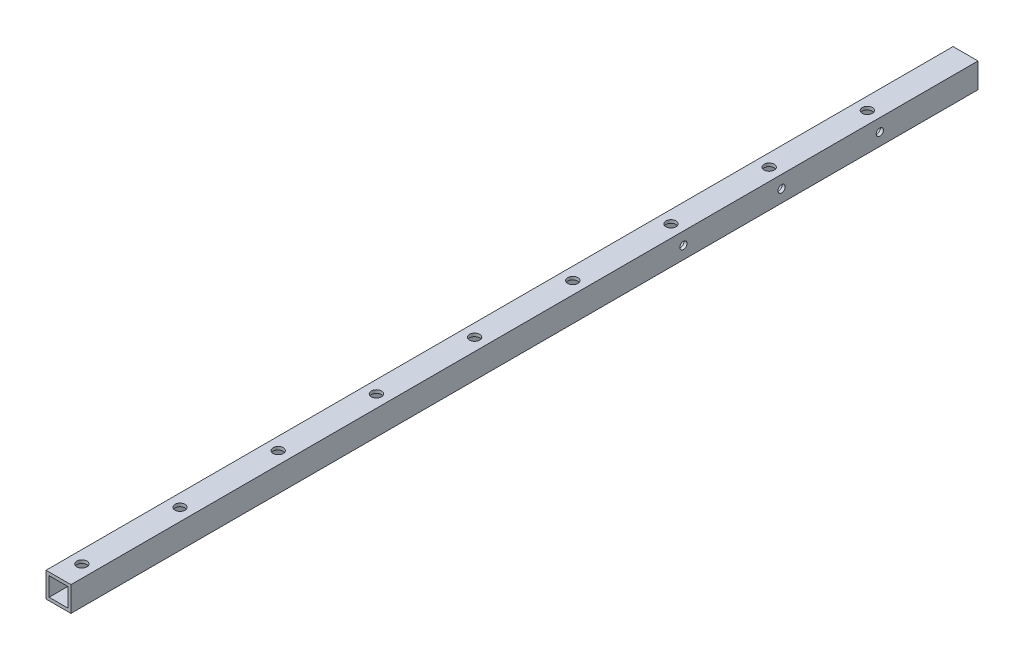
from build123d import *

# Parameters (mm, degrees)
SKETCH1_W           = 25.4
SKETCH1_H           = 25.4
SKETCH1_W_2         = 19.05
SKETCH1_H_2         = 19.05
BOSS_EXTRUDE1_DEPTH = 923.8
SKETCH2_R           = 5.175
CUT_EXTRUDE1_DEPTH  = 26.4
SKETCH3_R           = 3.675
CUT_EXTRUDE2_DEPTH  = 26.4


with BuildPart() as part:
    # Sketch1 → Boss-Extrude1 (new body)
    with BuildSketch(Plane.XY):
        Rectangle(SKETCH1_W, SKETCH1_H)
        Rectangle(SKETCH1_W_2, SKETCH1_H_2, mode=Mode.SUBTRACT)
    extrude(amount=BOSS_EXTRUDE1_DEPTH)

    # Sketch2 → Cut-Extrude1 (cut, through all)
    with BuildSketch(Plane(origin=(0, 12.7, 0), x_dir=(1, 0, 0), z_dir=(0, 1, 0))):
        with Locations((0, -100)):
            Circle(SKETCH2_R)
        with Locations((0, -200)):
            Circle(SKETCH2_R)
        with Locations((0, -300)):
            Circle(SKETCH2_R)
        with Locations((0, -400)):
            Circle(SKETCH2_R)
        with Locations((0, -500)):
            Circle(SKETCH2_R)
        with Locations((0, -600)):
            Circle(SKETCH2_R)
        with Locations((0, -700)):
            Circle(SKETCH2_R)
        with Locations((0, -800)):
            Circle(SKETCH2_R)
        with Locations((0, -900)):
            Circle(SKETCH2_R)
    extrude(amount=-CUT_EXTRUDE1_DEPTH, mode=Mode.SUBTRACT)

    # Sketch3 → Cut-Extrude2 (cut, through all)
    with BuildSketch(Plane.ZY.offset(12.7)):
        with Locations((100, 0)):
            Circle(SKETCH3_R)
        with Locations((200, 0)):
            Circle(SKETCH3_R)
        with Locations((300, 0)):
            Circle(SKETCH3_R)
    extrude(amount=-CUT_EXTRUDE2_DEPTH, mode=Mode.SUBTRACT)


solid = part.part
